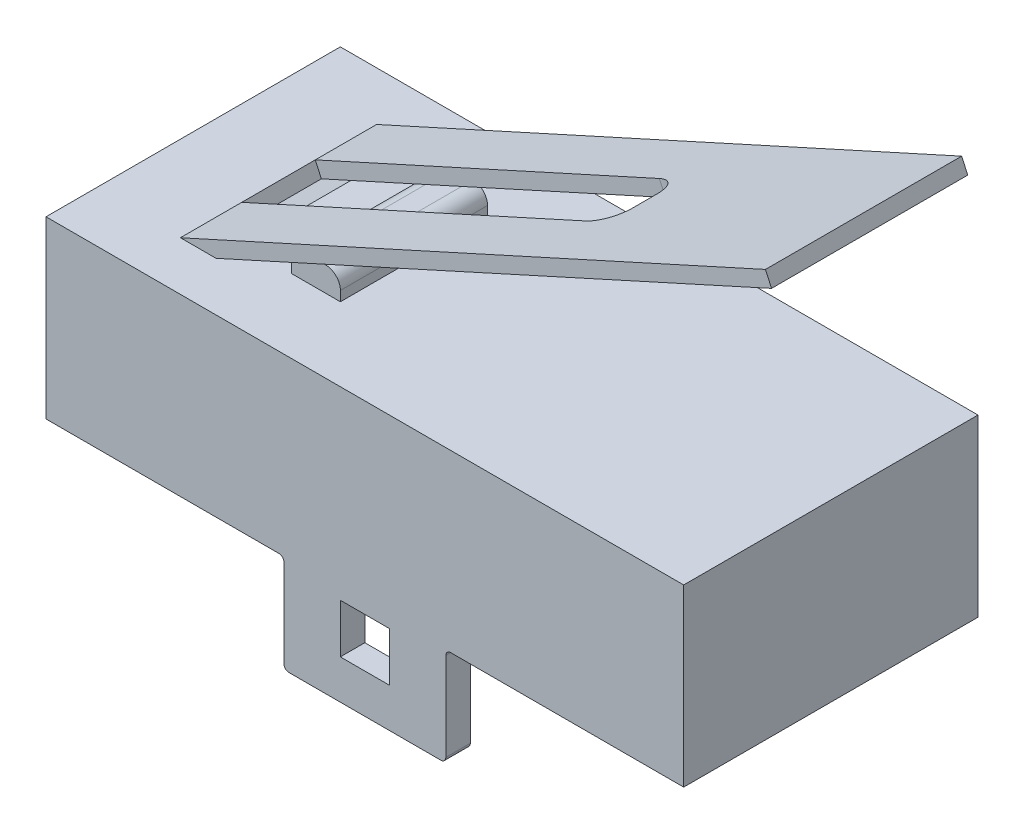
from build123d import *

# Parameters (mm, degrees)
SCHIZZO1_W                   = 13
SCHIZZO1_H                   = 3.57
ESTRUSIONE_ESTRUSIONE1_DEPTH = 6
SCHIZZO3_W                   = 3.3
SCHIZZO3_H                   = 0.5
ESTRUSIONE_ESTRUSIONE2_DEPTH = 2
RACCORDO1_R                  = 0.1
SCHIZZO4_W                   = 1
SCHIZZO4_H                   = 1
TAGLIO_ESTRUSIONE1_DEPTH     = 7
SCHIZZO5_W                   = 1.001424396
SCHIZZO5_H                   = 3
ESTRUSIONE_ESTRUSIONE3_DEPTH = 0.5
RACCORDO2_R                  = 0.3
ESTRUSIONE_ESTRUSIONE4_DEPTH = 4
TAGLIO_ESTRUSIONE2_DEPTH     = 0.3


with BuildPart() as part:
    # Schizzo1 → Estrusione-Estrusione1 (new body)
    with BuildSketch(Plane.XY):
        Rectangle(SCHIZZO1_W, SCHIZZO1_H)
    extrude(amount=ESTRUSIONE_ESTRUSIONE1_DEPTH)

    # Schizzo3 → Estrusione-Estrusione2 (add)
    with BuildSketch(Plane.XZ.offset(1.785)):
        with Locations((0, 5.75)):
            Rectangle(SCHIZZO3_W, SCHIZZO3_H)
        with Locations((0, 0.25)):
            Rectangle(SCHIZZO3_W, SCHIZZO3_H)
    extrude(amount=ESTRUSIONE_ESTRUSIONE2_DEPTH)

    # Raccordo1
    raccordo1_edges = [part.edges().sort_by_distance(p)[0] for p in [
        (1.65, -3.785, 0.25),
        (-1.65, -3.785, 0.25),
        (-1.65, -3.785, 5.75),
        (1.65, -3.785, 5.75),
        (-1.65, -1.785, 0.25),
        (1.65, -1.785, 0.25),
        (-1.65, -1.785, 5.75),
        (1.65, -1.785, 5.75),
    ]]
    fillet(raccordo1_edges, radius=RACCORDO1_R)

    # Schizzo4 → Taglio-Estrusione1 (cut, through all)
    with BuildSketch(Plane.XY.offset(6)):
        with Locations((0, -2.485)):
            Rectangle(SCHIZZO4_W, SCHIZZO4_H)
    extrude(amount=-TAGLIO_ESTRUSIONE1_DEPTH, mode=Mode.SUBTRACT)

    # Schizzo5 → Estrusione-Estrusione3 (add)
    with BuildSketch(Plane(origin=(0, 1.785, 0), x_dir=(1, 0, 0), z_dir=(0, 1, 0))):
        with Locations((-2.499287802, -3)):
            Rectangle(SCHIZZO5_W, SCHIZZO5_H)
    extrude(amount=ESTRUSIONE_ESTRUSIONE3_DEPTH)

    # Raccordo2
    raccordo2_edges = [part.edges().sort_by_distance(p)[0] for p in [
        (-3, 2.285, 3),
        (-1.998575604, 2.285, 3),
    ]]
    fillet(raccordo2_edges, radius=RACCORDO2_R)

    # Schizzo7 → Estrusione-Estrusione4 (add)
    with BuildSketch(Plane.XY.offset(5)):
        Polygon((-5.428309071, 1.15280402), (7.290989084, 6.916004863), (7.167174091, 7.189262704), (-5.552124064, 1.42606186), align=None)
    extrude(amount=-ESTRUSIONE_ESTRUSIONE4_DEPTH)

    # Schizzo8 → Taglio-Estrusione2 (cut)
    with BuildSketch(Plane(origin=(-1.481816175, 3.270346158, 0), x_dir=(0.910859468, 0.412716645, 0), z_dir=(-0.412716645, 0.910859468, 0))):
        with BuildLine():
            Line((-3.598949006, -2.25), (4.101050994, -2.25))
            ThreePointArc((4.101050994, -2.25), (4.454604385, -2.396446609), (4.601050994, -2.75))
            Line((4.601050994, -2.75), (4.601050994, -3.25))
            ThreePointArc((4.601050994, -3.25), (4.454604385, -3.603553391), (4.101050994, -3.75))
            Line((4.101050994, -3.75), (-3.598949006, -3.75))
            Line((-3.598949006, -3.75), (-3.598949006, -2.25))
        make_face()
    extrude(amount=-TAGLIO_ESTRUSIONE2_DEPTH, mode=Mode.SUBTRACT)


solid = part.part
